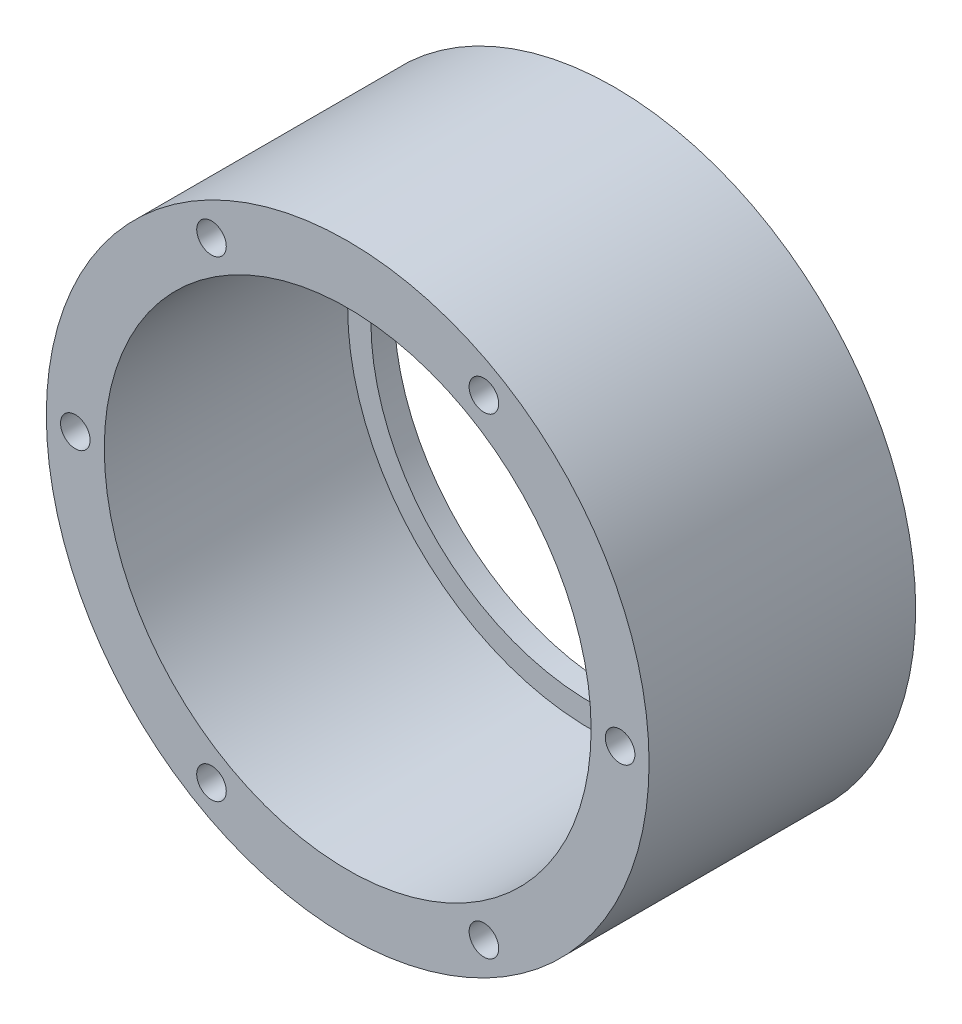
from build123d import *

# Parameters (mm, degrees)
PATTERN_CIRCULAR_1_COUNT = 6


with BuildPart() as part:
    # Эскиз1 → Повернуть1 (revolve)
    with BuildSketch(Plane(origin=(0, 0, 0), x_dir=(0, 0, -1), z_dir=(1, 0, 0))):
        Polygon((0, 26), (23, 26), (23, 19), (21, 19), (21, 21), (0, 21), align=None)
    revolve(axis=Axis((0, 0, 0), (0, 0, -1)))

    # Эскиз3 → Сверло под метчик  спиральное M2.51 (revolve, cut)
    with BuildSketch(Plane(origin=(23.5, 0, 0), x_dir=(0, -1, 0), z_dir=(1, 0, 0))):
        Polygon((0, 0), (0, 8.766097289), (1.275, 8), (1.275, 0), align=None)
    hole_wizard_m2_51 = revolve(axis=Axis((23.5, 0, 6.35), (0, 0, -1)), mode=Mode.SUBTRACT)

    # Круговой массив1: Сверло под метчик  спиральное M2.51 ×6 about axis
    pattern_circular_1_axis = Axis((0, 0, 0), (0, 0, 1))
    for i in range(1, PATTERN_CIRCULAR_1_COUNT):
        add(hole_wizard_m2_51.rotate(pattern_circular_1_axis, i * 360 / PATTERN_CIRCULAR_1_COUNT), mode=Mode.SUBTRACT)


solid = part.part
